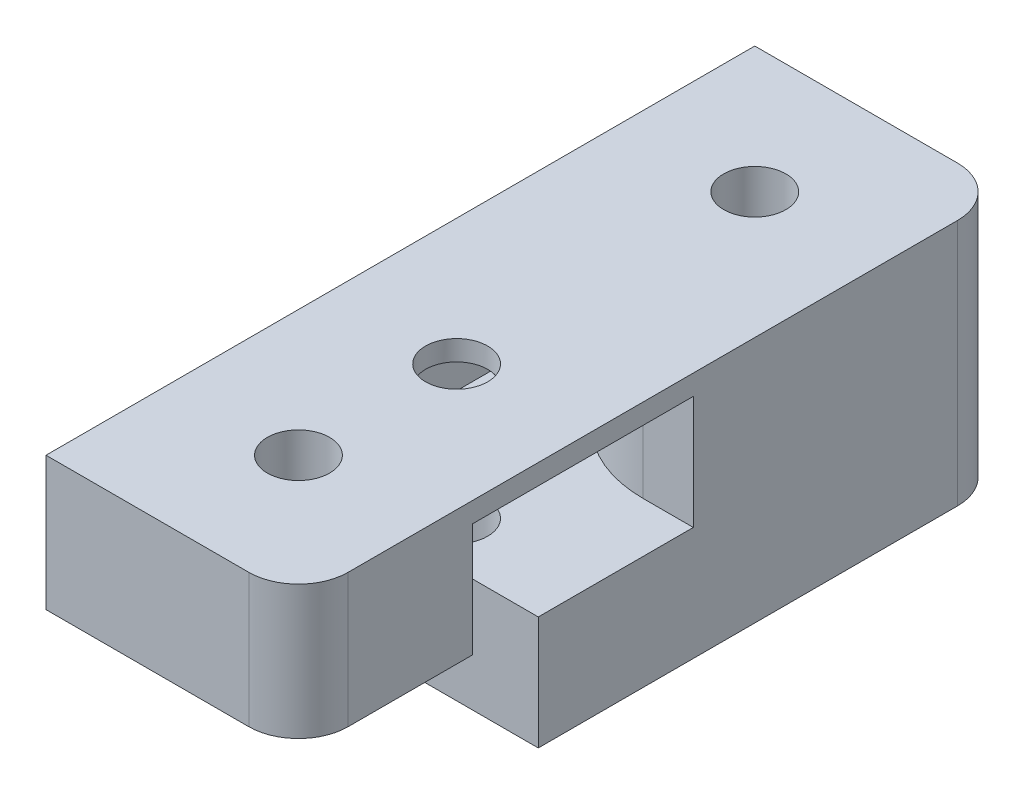
from build123d import *

# Parameters (mm, degrees)
SKETCH1_W           = 20.32
SKETCH1_H           = 57.05
SKETCH1_R           = 2.5
BOSS_EXTRUDE1_DEPTH = 19.9
FILLET1_R           = 4
CUT_EXTRUDE1_DEPTH  = 9.136
SKETCH3_R           = 2.5
CUT_EXTRUDE2_DEPTH  = 20.9
CUT_EXTRUDE3_START  = -10.764
CUT_EXTRUDE3_DEPTH  = 9.136
FILLET2_R           = 1


with BuildPart() as part:
    # Sketch1 → Boss-Extrude1 (new body)
    with BuildSketch(Plane(origin=(0, 0, 0), x_dir=(1, 0, 0), z_dir=(0, 1, 0))):
        with Locations((0, 18.365)):
            Rectangle(SKETCH1_W, SKETCH1_H)
        Circle(SKETCH1_R, mode=Mode.SUBTRACT)
        with Locations((0, 36.73)):
            Circle(SKETCH1_R, mode=Mode.SUBTRACT)
    extrude(amount=BOSS_EXTRUDE1_DEPTH)

    # Fillet1
    fillet1_edges = [part.edges().sort_by_distance(p)[0] for p in [
        (10.16, 9.95, 10.16),
        (10.16, 9.95, -46.89),
    ]]
    fillet(fillet1_edges, radius=FILLET1_R)

    # Sketch2 → Cut-Extrude1 (cut)
    with BuildSketch(Plane.XZ):
        with BuildLine():
            Line((-1.016, -9.144), (10.16, -9.144))
            Line((10.16, -9.144), (10.16, 10.16))
            Line((10.16, 10.16), (-10.16, 10.16))
            Line((-10.16, 10.16), (-10.16, 0))
            ThreePointArc((-10.16, 0), (-7.481784407, -6.465784407), (-1.016, -9.144))
        make_face()
    extrude(amount=-CUT_EXTRUDE1_DEPTH, mode=Mode.SUBTRACT)

    # Sketch3 → Cut-Extrude2 (cut, through all)
    with BuildSketch(Plane(origin=(0, 19.9, 0), x_dir=(1, 0, 0), z_dir=(0, 1, 0))):
        with Locations((0, 12.73)):
            Circle(SKETCH3_R)
    extrude(amount=-CUT_EXTRUDE2_DEPTH, mode=Mode.SUBTRACT)

    # Sketch4 → Cut-Extrude3 (cut)
    with BuildSketch(Plane(origin=(0, 19.9, 0), x_dir=(1, 0, 0), z_dir=(0, 1, 0)).offset(CUT_EXTRUDE3_START)):
        with BuildLine():
            Line((0, 3.84), (10.16, 3.84))
            Line((10.16, 3.84), (10.16, 21.62))
            Line((10.16, 21.62), (6.11, 21.62))
            ThreePointArc((6.11, 21.62), (-0.961067812, 24.548932188), (-3.89, 31.62))
            Line((-3.89, 31.62), (-3.89, 46.89))
            Line((-3.89, 46.89), (-8.89, 46.89))
            Line((-8.89, 46.89), (-8.89, 12.73))
            ThreePointArc((-8.89, 12.73), (-6.286179285, 6.443820715), (0, 3.84))
        make_face()
    extrude(amount=CUT_EXTRUDE3_DEPTH, mode=Mode.SUBTRACT)

    # Fillet2
    fillet2_edges = [part.edges().sort_by_distance(p)[0] for p in [
        (-10.16, 4.568, 0),
    ]]
    fillet(fillet2_edges, radius=FILLET2_R)


solid = part.part
